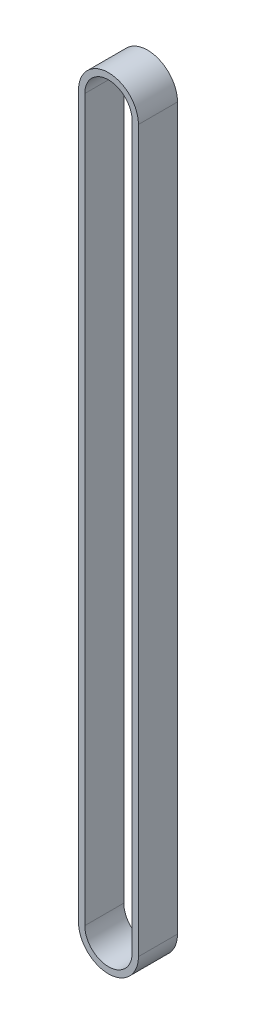
from build123d import *

# Parameters (mm, degrees)
BOSS_EXTRUDE1_DEPTH = 7.5


with BuildPart() as part:
    # Sketch1 → Boss-Extrude1 (new body, symmetric)
    with BuildSketch(Plane.XY):
        with BuildLine():
            Line((11.505, 201.15329588), (11.505, -75.63670412))
            ThreePointArc((11.505, -75.63670412), (0, -87.14170412), (-11.505, -75.63670412))
            Line((-11.505, -75.63670412), (-11.505, 201.15329588))
            ThreePointArc((-11.505, 201.15329588), (0, 212.65829588), (11.505, 201.15329588))
        make_face()
        with BuildLine():
            Line((9.105, 201.15329588), (9.105, -75.63670412))
            ThreePointArc((9.105, -75.63670412), (0, -84.74170412), (-9.105, -75.63670412))
            Line((-9.105, -75.63670412), (-9.105, 201.15329588))
            ThreePointArc((-9.105, 201.15329588), (0, 210.25829588), (9.105, 201.15329588))
        make_face(mode=Mode.SUBTRACT)
    extrude(amount=BOSS_EXTRUDE1_DEPTH, both=True)


solid = part.part
